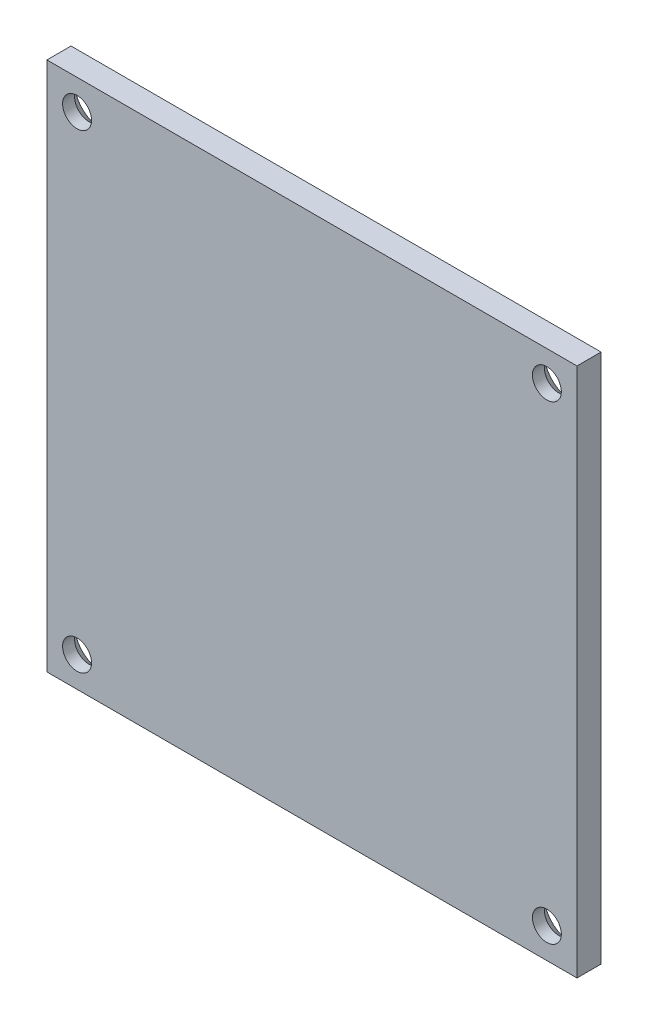
from build123d import *

# Parameters (mm, degrees)
ESQUISSE1_W                                 = 44
ESQUISSE1_H                                 = 44
BOSS_EXTRU_1_DEPTH                          = 2
FRAISAGE_POUR_VIS_T_TE_FRAIS_E_M21_AT_COUNT = 2
FRAISAGE_POUR_VIS_T_TE_FRAIS_E_M21_AT_PITCH = 39


with BuildPart() as part:
    # Esquisse1 → Boss.-Extru.1 (new body)
    with BuildSketch(Plane(origin=(0, 0, 0), x_dir=(0, 1, 0), z_dir=(0, 0, 1))):
        Rectangle(ESQUISSE1_W, ESQUISSE1_H)
    extrude(amount=BOSS_EXTRU_1_DEPTH)

    # Esquisse3 → Fraisage pour vis à tête fraisée M21 (revolve, cut)
    with BuildSketch(Plane(origin=(19.5, 19.5, 0), x_dir=(0, 1, 0), z_dir=(1, 0, 0))):
        Polygon((0, 0), (0, 2), (1.2, 2), (1.2, 1), (2.2, 0), align=None)
    fraisage_pour_vis_t_te_frais_e_m21 = revolve(axis=Axis((19.5, 19.5, -6.35), (0, 0, 1)), mode=Mode.SUBTRACT)

    # Fraisage pour vis à tête fraisée M21 at: Fraisage pour vis à tête fraisée M21 ×2
    with Locations(*[(-i * FRAISAGE_POUR_VIS_T_TE_FRAIS_E_M21_AT_PITCH, 0, 0) for i in range(1, FRAISAGE_POUR_VIS_T_TE_FRAIS_E_M21_AT_COUNT)]):
        add(fraisage_pour_vis_t_te_frais_e_m21, mode=Mode.SUBTRACT)

    # Symétrie2: Fraisage pour vis à tête fraisée M21 across plane
    add(fraisage_pour_vis_t_te_frais_e_m21.mirror(Plane.ZX), mode=Mode.SUBTRACT)

    # Symétrie2 copy 1 sketch → Symétrie2 copy 1 (revolve, cut)
    with BuildSketch(Plane(origin=(-19.5, -19.5, 0), x_dir=(0, -1, 0), z_dir=(1, 0, 0))):
        Polygon((0, 0), (0, -2), (1.2, -2), (1.2, -1), (2.2, 0), align=None)
    revolve(axis=Axis((-19.5, -19.5, -6.35), (0, 0, -1)), mode=Mode.SUBTRACT)


solid = part.part
